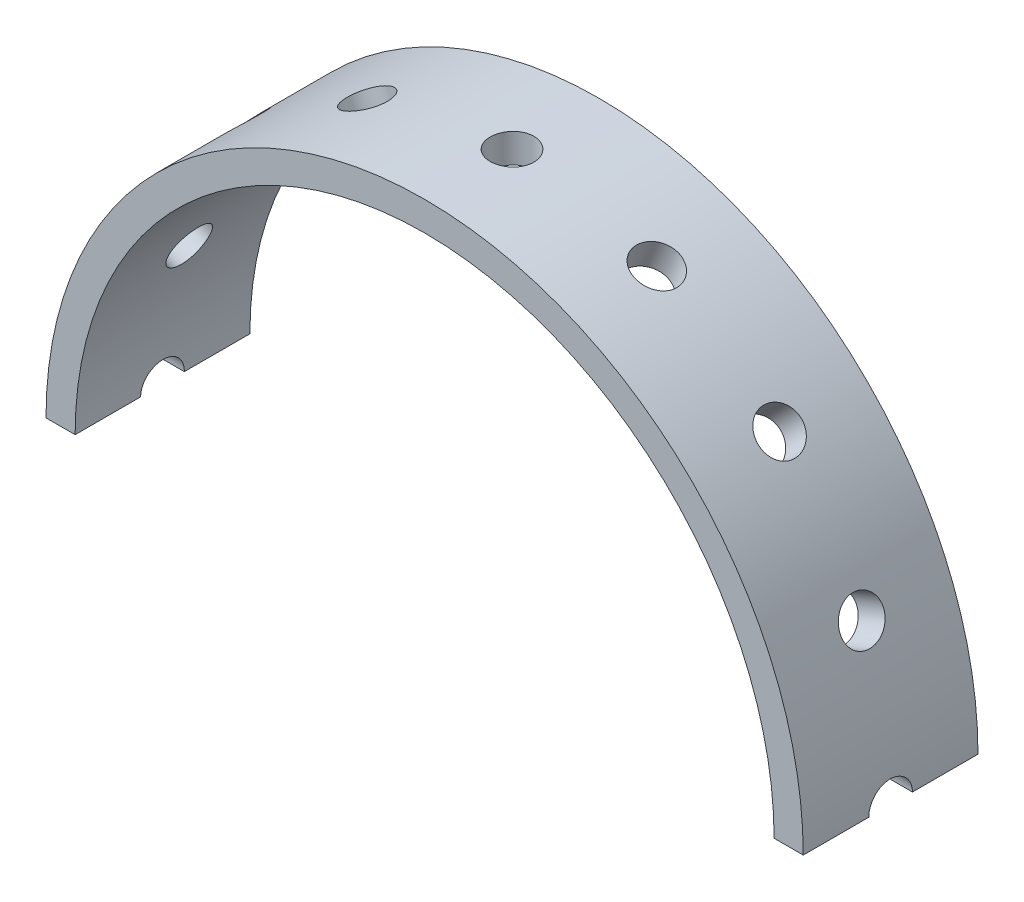
from build123d import *

# Parameters (mm, degrees)
SKETCH_1_R               = 13
SKETCH_1_R_2             = 12
EXTRUDE_1_DEPTH          = 6
SKETCH_2_R               = 0.75
CUT_EXTRUDE_1_DEPTH      = 14
PATTERN_CIRCULAR_1_COUNT = 16
SKETCH_3_W               = 36.79853237
SKETCH_3_H               = 11.94610836
CUT_EXTRUDE_2_DEPTH      = 14.0000001


with BuildPart() as part:
    # ｽｹｯﾁ1 → ﾎﾞｽ - 押し出し1 (new body)
    with BuildSketch(Plane.XY):
        Circle(SKETCH_1_R)
        Circle(SKETCH_1_R_2, mode=Mode.SUBTRACT)
    extrude(amount=EXTRUDE_1_DEPTH)

    # ｽｹｯﾁ2 → ｶｯﾄ - 押し出し1 (cut, through all)
    with BuildSketch(Plane(origin=(0, 0, 0), x_dir=(1, 0, 0), z_dir=(0, 1, 0))):
        with Locations((0, -3)):
            Circle(SKETCH_2_R)
    cut_extrude_1 = extrude(amount=-CUT_EXTRUDE_1_DEPTH, mode=Mode.SUBTRACT)

    # 円形ﾊﾟﾀｰﾝ1: ｶｯﾄ - 押し出し1 ×16 about axis
    pattern_circular_1_axis = Axis((0, 0, 0), (0, 0, 1))
    for i in range(1, PATTERN_CIRCULAR_1_COUNT):
        add(cut_extrude_1.rotate(pattern_circular_1_axis, i * 360 / PATTERN_CIRCULAR_1_COUNT), mode=Mode.SUBTRACT)

    # ｽｹｯﾁ3 → ｶｯﾄ - 押し出し2 (cut, through all)
    with BuildSketch(Plane(origin=(0, 0, 0), x_dir=(1, 0, 0), z_dir=(0, 1, 0))):
        with Locations((0, -2.028241391)):
            Rectangle(SKETCH_3_W, SKETCH_3_H)
    extrude(amount=-CUT_EXTRUDE_2_DEPTH, mode=Mode.SUBTRACT)


solid = part.part
